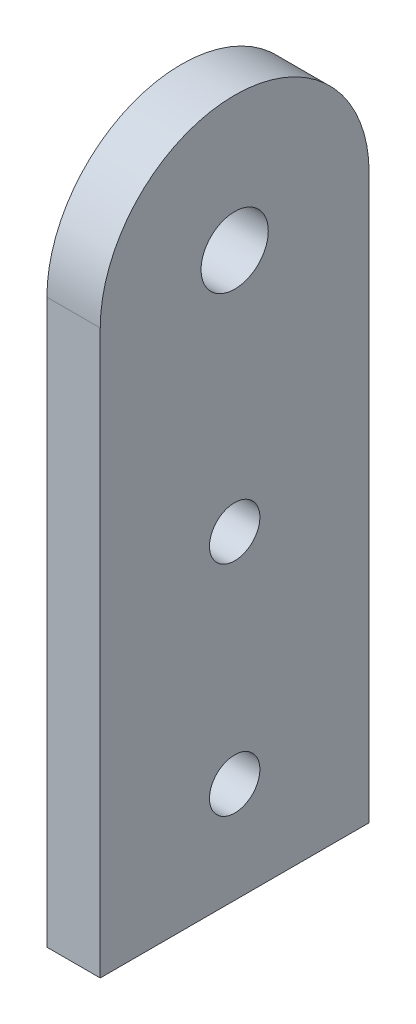
from build123d import *

# Parameters (mm, degrees)
SKETCH1_R           = 2
SKETCH1_R_2         = 1.5
BOSS_EXTRUDE1_DEPTH = 3.175


with BuildPart() as part:
    # Sketch1 → Boss-Extrude1 (new body)
    with BuildSketch(Plane(origin=(0, 0, 0), x_dir=(0, 0, -1), z_dir=(1, 0, 0))):
        with BuildLine():
            Line((-8, 0), (-8, -33.5))
            Line((-8, -33.5), (8, -33.5))
            Line((8, -33.5), (8, 0))
            ThreePointArc((8, 0), (0, 8), (-8, 0))
        make_face()
        Circle(SKETCH1_R, mode=Mode.SUBTRACT)
        with Locations((0, -14.5)):
            Circle(SKETCH1_R_2, mode=Mode.SUBTRACT)
        with Locations((0, -27.5)):
            Circle(SKETCH1_R_2, mode=Mode.SUBTRACT)
    extrude(amount=BOSS_EXTRUDE1_DEPTH)


solid = part.part
